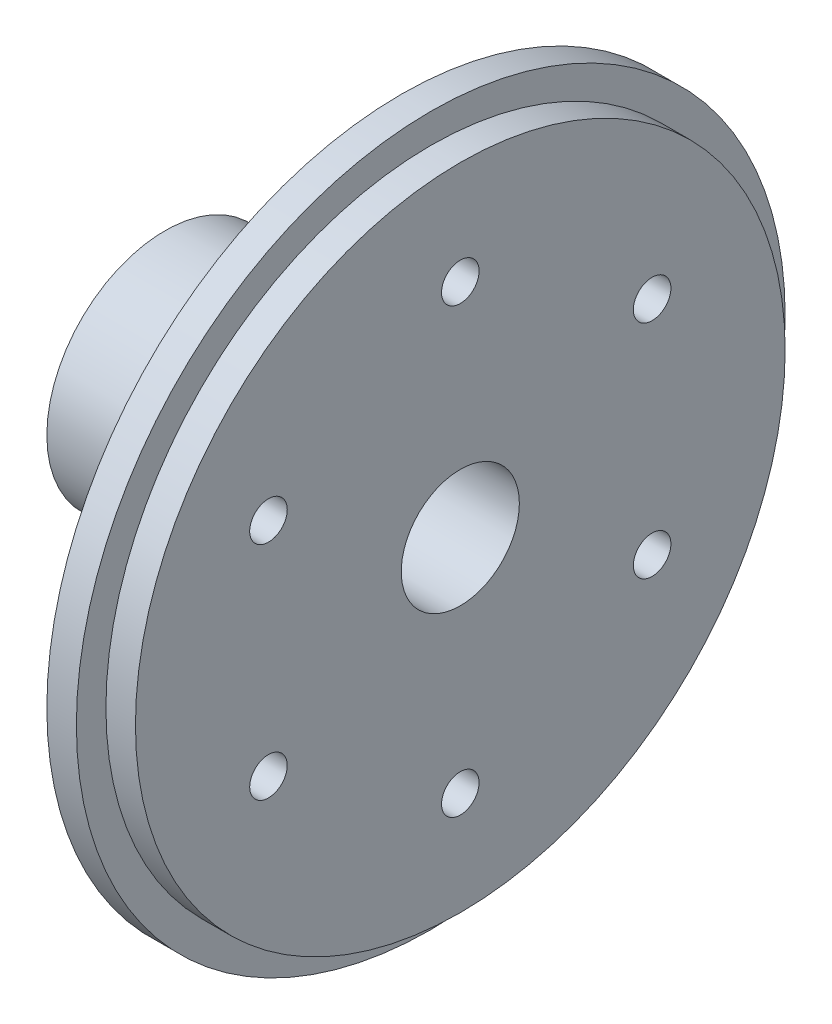
from build123d import *

# Parameters (mm, degrees)
SKETCH1_R                  = 38.1
BOSS_EXTRUDE1_DEPTH        = 6.35
SKETCH3_R                  = 38.1
SKETCH3_R_2                = 34.925
CUT_EXTRUDE_THIN1_DEPTH    = 3.175
SKETCH8_R                  = 12.7
BOSS_EXTRUDE2_DEPTH        = 25.4
F_1_2_0_5_DIAMETER_HOLE1_D = 12.7
F_10_32_TAPPED_HOLE1_D     = 4.0386
CIRPATTERN1_COUNT          = 6


with BuildPart() as part:
    # Sketch1 → Boss-Extrude1 (new body)
    with BuildSketch(Plane(origin=(0, 0, 0), x_dir=(0, 0, -1), z_dir=(1, 0, 0))):
        Circle(SKETCH1_R)
    extrude(amount=BOSS_EXTRUDE1_DEPTH)

    # Sketch3 → Cut-Extrude-Thin1 (cut)
    with BuildSketch(Plane(origin=(6.35, 0, 0), x_dir=(0, 0, -1), z_dir=(1, 0, 0))):
        Circle(SKETCH3_R)
        Circle(SKETCH3_R_2, mode=Mode.SUBTRACT)
    extrude(amount=-CUT_EXTRUDE_THIN1_DEPTH, mode=Mode.SUBTRACT)

    # Sketch8 → Boss-Extrude2 (add)
    with BuildSketch(Plane.ZY):
        Circle(SKETCH8_R)
    extrude(amount=BOSS_EXTRUDE2_DEPTH)

    # 1/2 (0.5) Diameter Hole1 (through all)
    with Locations(Plane(origin=(6.35, 0, 0), x_dir=(0, 0, -1), z_dir=(1, 0, 0))):
        with Locations((0, 0)):
            Hole(F_1_2_0_5_DIAMETER_HOLE1_D / 2)

    # #10-32 Tapped Hole1 (through all)
    with Locations(Plane.ZY):
        with Locations((0, 23.8125)):
            f_10_32_tapped_hole1 = Hole(F_10_32_TAPPED_HOLE1_D / 2)

    # CirPattern1: #10-32 Tapped Hole1 ×6 about axis
    cirpattern1_axis = Axis((0, 0, 0), (1, 0, 0))
    for i in range(1, CIRPATTERN1_COUNT):
        add(f_10_32_tapped_hole1.rotate(cirpattern1_axis, i * 360 / CIRPATTERN1_COUNT), mode=Mode.SUBTRACT)


solid = part.part
